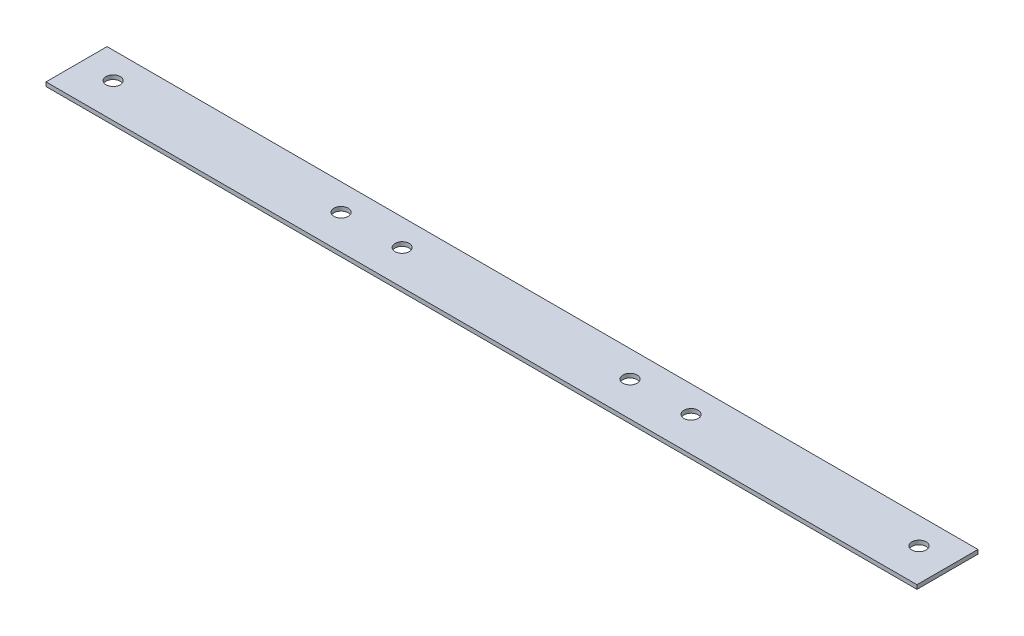
from build123d import *

# Parameters (mm, degrees)
SKETCH_1_W      = 214
SKETCH_1_H      = 15
SKETCH_1_R      = 1.75
EXTRUDE_1_DEPTH = 1


with BuildPart() as part:
    # Эскиз1 → Бобышка-Вытянуть1 (new body)
    with BuildSketch(Plane(origin=(0, 0, 0), x_dir=(1, 0, 0), z_dir=(0, 1, 0))):
        with Locations((107, 7.5)):
            Rectangle(SKETCH_1_W, SKETCH_1_H)
        with Locations((64, 8.5)):
            Circle(SKETCH_1_R, mode=Mode.SUBTRACT)
        with Locations((8, 8.5)):
            Circle(SKETCH_1_R, mode=Mode.SUBTRACT)
        with Locations((79, 8.5)):
            Circle(SKETCH_1_R, mode=Mode.SUBTRACT)
        with Locations((135, 8.5)):
            Circle(SKETCH_1_R, mode=Mode.SUBTRACT)
        with Locations((150, 8.5)):
            Circle(SKETCH_1_R, mode=Mode.SUBTRACT)
        with Locations((206, 8.5)):
            Circle(SKETCH_1_R, mode=Mode.SUBTRACT)
    extrude(amount=EXTRUDE_1_DEPTH)


solid = part.part
